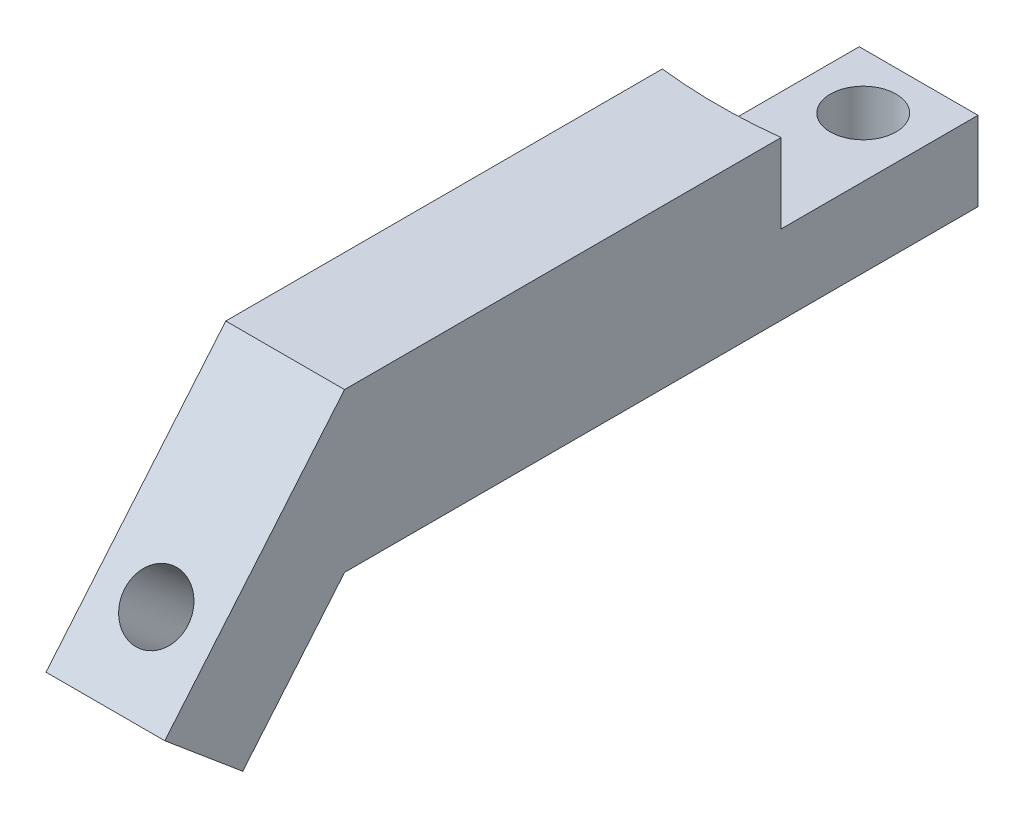
from build123d import *

# Parameters (mm, degrees)
SKETCH1_W           = 15
SKETCH1_H           = 80
SKETCH1_R           = 4.15
BOSS_EXTRUDE1_DEPTH = 10
BOSS_EXTRUDE2_DEPTH = 10
BOSS_EXTRUDE4_DEPTH = 15
SKETCH11_R          = 4
CUT_EXTRUDE5_DEPTH  = 31.247894791


with BuildPart() as part:
    # Sketch1 → Boss-Extrude1 (new body)
    with BuildSketch(Plane(origin=(0, 0, 0), x_dir=(1, 0, 0), z_dir=(0, 1, 0))):
        Rectangle(SKETCH1_W, SKETCH1_H)
        with Locations(Location((0, 33, 0), (0, 0, 270))):  # turned: the seam where the file's is
            Circle(SKETCH1_R, mode=Mode.SUBTRACT)
    extrude(amount=BOSS_EXTRUDE1_DEPTH)

    # Sketch2 → Boss-Extrude2 (add)
    with BuildSketch(Plane(origin=(0, 10, 0), x_dir=(1, 0, 0), z_dir=(0, 1, 0))):
        with BuildLine():
            Line((7.5, 15.134142149), (7.5, -40))
            Line((7.5, -40), (-7.5, -40))
            Line((-7.5, -40), (-7.5, 15.134142149))
            ThreePointArc((-7.5, 15.134142149), (0, 14.7), (7.5, 15.134142149))
        make_face()
    extrude(amount=BOSS_EXTRUDE2_DEPTH)

    # Sketch10 → Boss-Extrude4 (add)
    with BuildSketch(Plane(origin=(7.5, 0, 0), x_dir=(0, 0, -1), z_dir=(1, 0, 0))):
        Polygon((-40, 0), (-52.855752194, -15.320888862), (-62.703829724, -7.057370639), (-40, 20), align=None)
    extrude(amount=-BOSS_EXTRUDE4_DEPTH)

    # Sketch11 → Cut-Extrude5 (cut, through all)
    with BuildSketch(Plane(origin=(0, 19.69615506, 23.472963553), x_dir=(-1, 0, 0), z_dir=(0, -0.64278761, -0.766044443))):
        with Locations(Location((0, -35.711504387, 0), (0, 0, 90))):  # turned: the seam where the file's is
            Circle(SKETCH11_R)
    extrude(amount=-CUT_EXTRUDE5_DEPTH, mode=Mode.SUBTRACT)


solid = part.part
